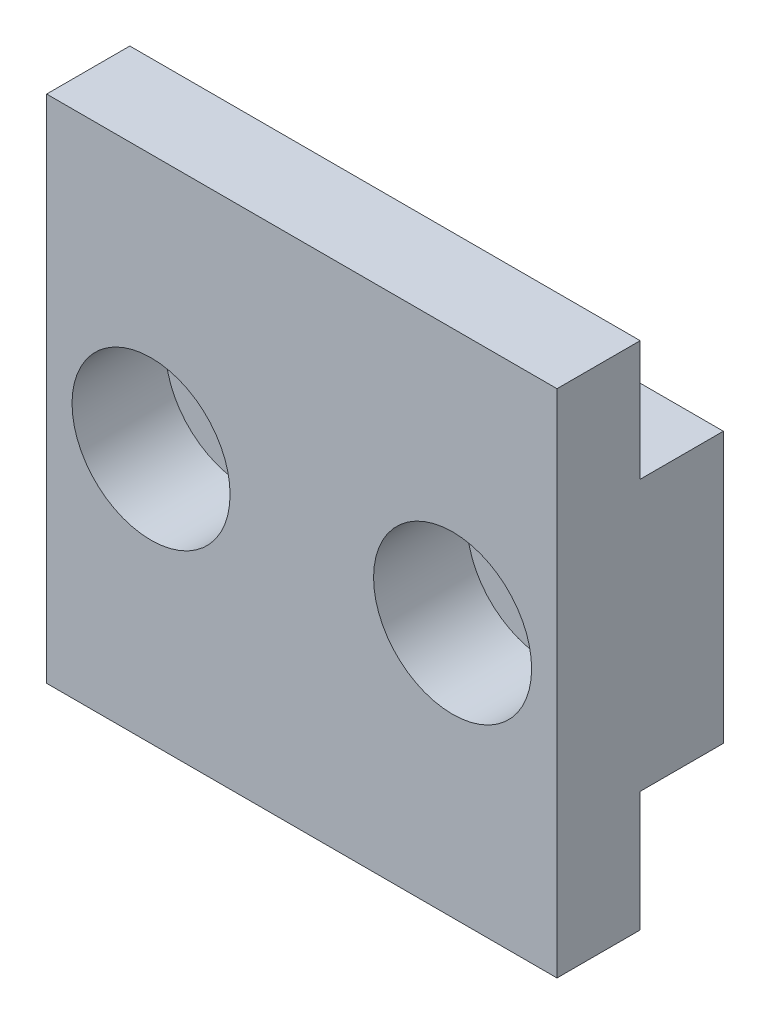
from build123d import *

# Parameters (mm, degrees)
SKETCH1_W           = 24.542
SKETCH1_H           = 13
BOSS_EXTRUDE1_DEPTH = 4
SKETCH2_W           = 24.542
SKETCH2_H           = 24.542
BOSS_EXTRUDE2_DEPTH = 4
SKETCH3_R           = 2.3
CUT_EXTRUDE1_DEPTH  = 9
SKETCH4_R           = 3.8
CUT_EXTRUDE2_DEPTH  = 4.5


with BuildPart() as part:
    # Sketch1 → Boss-Extrude1 (new body)
    with BuildSketch(Plane.XY):
        with Locations((67.729, 6.5)):
            Rectangle(SKETCH1_W, SKETCH1_H)
    extrude(amount=BOSS_EXTRUDE1_DEPTH)

    # Sketch2 → Boss-Extrude2 (add)
    with BuildSketch(Plane.XY.offset(4)):
        with Locations((67.729, 6.5)):
            Rectangle(SKETCH2_W, SKETCH2_H)
    extrude(amount=BOSS_EXTRUDE2_DEPTH)

    # Sketch3 → Cut-Extrude1 (cut, through all)
    with BuildSketch(Plane(origin=(0, 0, 0), x_dir=(-1, 0, 0), z_dir=(0, 0, -1))):
        with Locations((-60.479, 6.5)):
            Circle(SKETCH3_R)
        with Locations((-74.979, 6.5)):
            Circle(SKETCH3_R)
    extrude(amount=-CUT_EXTRUDE1_DEPTH, mode=Mode.SUBTRACT)

    # Sketch4 → Cut-Extrude2 (cut)
    with BuildSketch(Plane.XY.offset(8)):
        with Locations((60.479, 6.5)):
            Circle(SKETCH4_R)
        with Locations((74.979, 6.5)):
            Circle(SKETCH4_R)
    extrude(amount=-CUT_EXTRUDE2_DEPTH, mode=Mode.SUBTRACT)


solid = part.part
